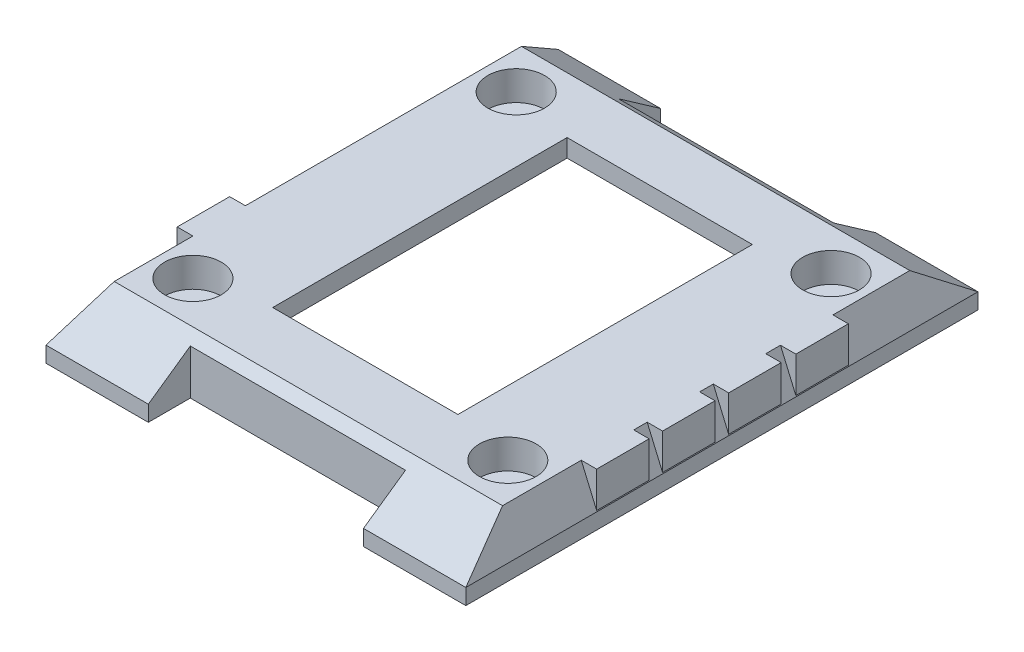
from build123d import *

# Parameters (mm, degrees)
SKETCH1_W            = 40
SKETCH1_H            = 48.8
BOSS_EXTRUDE1_DEPTH  = 5
SKETCH2_W            = 20.5
SKETCH2_H            = 8
CUT_EXTRUDE1_DEPTH   = 6
SKETCH3_R            = 2.7
CUT_EXTRUDE2_DEPTH   = 2.8
SKETCH5_R            = 1
CUT_EXTRUDE3_DEPTH   = 6
SKETCH6_OUTSIDE_W    = 63.46
SKETCH6_OUTSIDE_H    = 19.66
CUT_EXTRUDE4_DEPTH   = 41
SKETCH7_OUTSIDE_W    = 54.66
SKETCH7_OUTSIDE_H    = 19.66
CUT_EXTRUDE5_DEPTH   = 49.8
SKETCH8_W            = 17.65
SKETCH8_H            = 28.05
CUT_EXTRUDE6_DEPTH   = 6
BOSS_EXTRUDE2_REACH  = 7
SKETCH9_W            = 2.93050761
SKETCH9_H            = 5
SKETCH9_W_2          = 3
SKETCH10_W           = 35.8
SKETCH10_H           = 38
CUT_EXTRUDE7_DEPTH   = 0.8
SKETCH11_W           = 36
SKETCH11_H           = 24
CUT_EXTRUDE8_DEPTH   = 2.8
SKETCH12_W           = 4
SKETCH12_H           = 26.7
CUT_EXTRUDE9_DEPTH   = 3.3
SKETCH13_OUTSIDE_W   = 54.66
SKETCH13_OUTSIDE_H   = 63.46
SKETCH13_OUTSIDE_W_2 = 40
SKETCH13_OUTSIDE_H_2 = 48.8
CUT_EXTRUDE10_DEPTH  = 3.3
SKETCH14_W           = 3.8
SKETCH14_H           = 4.5
FILLET1_R            = 2


with BuildPart() as part:
    # Sketch1 → Boss-Extrude1 (new body)
    with BuildSketch(Plane(origin=(0, 0, 0), x_dir=(1, 0, 0), z_dir=(0, 1, 0))):
        with Locations((-15.144927536, 0.78115942)):
            Rectangle(SKETCH1_W, SKETCH1_H)
    extrude(amount=BOSS_EXTRUDE1_DEPTH)

    # Sketch2 → Cut-Extrude1 (cut, through all)
    with BuildSketch(Plane(origin=(0, 5, 0), x_dir=(1, 0, 0), z_dir=(0, 1, 0))):
        with Locations((-15.144927536, -23.61884058)):
            Rectangle(SKETCH2_W, SKETCH2_H)
        with Locations((-15.144927536, 25.18115942)):
            Rectangle(SKETCH2_W, SKETCH2_H)
    extrude(amount=-CUT_EXTRUDE1_DEPTH, mode=Mode.SUBTRACT)

    # Sketch3 → Cut-Extrude2 (cut)
    with BuildSketch(Plane(origin=(0, 5, 0), x_dir=(1, 0, 0), z_dir=(0, 1, 0))):
        with Locations((-30.144927536, 16.18115942)):
            Circle(SKETCH3_R)
        with Locations((-0.144927536, 16.18115942)):
            Circle(SKETCH3_R)
        with Locations((-30.144927536, -14.61884058)):
            Circle(SKETCH3_R)
        with Locations((-0.144927536, -14.61884058)):
            Circle(SKETCH3_R)
    extrude(amount=-CUT_EXTRUDE2_DEPTH, mode=Mode.SUBTRACT)

    # Sketch5 → Cut-Extrude3 (cut, through all)
    with BuildSketch(Plane(origin=(0, 5, 0), x_dir=(1, 0, 0), z_dir=(0, 1, 0))):
        with Locations((-30.144927536, -14.61884058)):
            Circle(SKETCH5_R)
        with Locations((-0.144927536, -14.61884058)):
            Circle(SKETCH5_R)
        with Locations((-0.144927536, 16.18115942)):
            Circle(SKETCH5_R)
        with Locations((-30.144927536, 16.18115942)):
            Circle(SKETCH5_R)
    extrude(amount=-CUT_EXTRUDE3_DEPTH, mode=Mode.SUBTRACT)

    # Sketch6 outside → Cut-Extrude4 (cut, through all)
    with BuildSketch(Plane(origin=(4.855072464, 0, 0), x_dir=(0, 0, -1), z_dir=(1, 0, 0))):
        with Locations((0.781, 2.5)):
            Rectangle(SKETCH6_OUTSIDE_W, SKETCH6_OUTSIDE_H)
        Polygon((-18.61884058, 5), (-23.61884058, 1.5), (-23.61884058, 0), (25.18115942, 0), (25.18115942, 1.5), (20.18115942, 5), align=None, mode=Mode.SUBTRACT)
    extrude(amount=-CUT_EXTRUDE4_DEPTH, mode=Mode.SUBTRACT)

    # Sketch7 outside → Cut-Extrude5 (cut, through all)
    with BuildSketch(Plane.XY.offset(23.61884058)):
        with Locations((-15.145, 2.5)):
            Rectangle(SKETCH7_OUTSIDE_W, SKETCH7_OUTSIDE_H)
        Polygon((4.855072464, 1.5), (3.355072464, 5), (-33.644927536, 5), (-35.144927536, 1.5), (-35.144927536, 0), (4.855072464, 0), align=None, mode=Mode.SUBTRACT)
    extrude(amount=-CUT_EXTRUDE5_DEPTH, mode=Mode.SUBTRACT)

    # Sketch8 → Cut-Extrude6 (cut, through all)
    with BuildSketch(Plane(origin=(0, 5, 0), x_dir=(1, 0, 0), z_dir=(0, 1, 0))):
        with Locations((-15.119927536, 0.80615942)):
            Rectangle(SKETCH8_W, SKETCH8_H)
    extrude(amount=-CUT_EXTRUDE6_DEPTH, mode=Mode.SUBTRACT)

    # Sketch9 → Boss-Extrude2 (add, up to next)
    with BuildSketch(Plane(origin=(0, 5, 0), x_dir=(1, 0, 0), z_dir=(0, 1, 0)), mode=Mode.PRIVATE) as boss_extrude2_sk1:
        with Locations((3.355072464, 10.36115942)):
            Rectangle(SKETCH9_W, SKETCH9_H)
    boss_extrude2_tool1 = extrude(boss_extrude2_sk1.sketch, amount=-BOSS_EXTRUDE2_REACH, mode=Mode.PRIVATE) - part.part
    add(boss_extrude2_tool1.solids().sort_by_distance((3.355072, 5, -10.361159))[0])
    # Sketch9 → Boss-Extrude2 (add, up to next)
    with BuildSketch(Plane(origin=(0, 5, 0), x_dir=(1, 0, 0), z_dir=(0, 1, 0)), mode=Mode.PRIVATE) as boss_extrude2_sk2:
        with Locations((3.355072464, 3.96115942)):
            Rectangle(SKETCH9_W, SKETCH9_H)
    boss_extrude2_tool2 = extrude(boss_extrude2_sk2.sketch, amount=-BOSS_EXTRUDE2_REACH, mode=Mode.PRIVATE) - part.part
    add(boss_extrude2_tool2.solids().sort_by_distance((3.355072, 5, -3.961159))[0])
    # Sketch9 → Boss-Extrude2 (add, up to next)
    with BuildSketch(Plane(origin=(0, 5, 0), x_dir=(1, 0, 0), z_dir=(0, 1, 0)), mode=Mode.PRIVATE) as boss_extrude2_sk3:
        with Locations((3.355072464, -2.33884058)):
            Rectangle(SKETCH9_W, SKETCH9_H)
    boss_extrude2_tool3 = extrude(boss_extrude2_sk3.sketch, amount=-BOSS_EXTRUDE2_REACH, mode=Mode.PRIVATE) - part.part
    add(boss_extrude2_tool3.solids().sort_by_distance((3.355072, 5, 2.338841))[0])
    # Sketch9 → Boss-Extrude2 (add, up to next)
    with BuildSketch(Plane(origin=(0, 5, 0), x_dir=(1, 0, 0), z_dir=(0, 1, 0)), mode=Mode.PRIVATE) as boss_extrude2_sk4:
        with Locations((3.355072464, -8.61884058)):
            Rectangle(SKETCH9_W, SKETCH9_H)
    boss_extrude2_tool4 = extrude(boss_extrude2_sk4.sketch, amount=-BOSS_EXTRUDE2_REACH, mode=Mode.PRIVATE) - part.part
    add(boss_extrude2_tool4.solids().sort_by_distance((3.355072, 5, 8.618841))[0])
    # Sketch9 → Boss-Extrude2 (add, up to next)
    with BuildSketch(Plane(origin=(0, 5, 0), x_dir=(1, 0, 0), z_dir=(0, 1, 0)), mode=Mode.PRIVATE) as boss_extrude2_sk5:
        with Locations((-33.644927536, -8.61884058)):
            Rectangle(SKETCH9_W_2, SKETCH9_H)
    boss_extrude2_tool5 = extrude(boss_extrude2_sk5.sketch, amount=-BOSS_EXTRUDE2_REACH, mode=Mode.PRIVATE) - part.part
    add(boss_extrude2_tool5.solids().sort_by_distance((-33.644928, 5, 8.618841))[0])

    # Sketch10 → Cut-Extrude7 (cut)
    with BuildSketch(Plane.XZ):
        with Locations((-15.144927536, -0.78115942)):
            Rectangle(SKETCH10_W, SKETCH10_H)
    extrude(amount=-CUT_EXTRUDE7_DEPTH, mode=Mode.SUBTRACT)

    # Sketch11 → Cut-Extrude8 (cut)
    with BuildSketch(Plane.XZ):
        with Locations((-15.144927536, -0.78115942)):
            Rectangle(SKETCH11_W, SKETCH11_H)
    extrude(amount=-CUT_EXTRUDE8_DEPTH, mode=Mode.SUBTRACT)

    # Sketch12 → Cut-Extrude9 (cut)
    with BuildSketch(Plane.XZ):
        with Locations((-5.144927536, -0.93115942)):
            Rectangle(SKETCH12_W, SKETCH12_H)
    extrude(amount=-CUT_EXTRUDE9_DEPTH, mode=Mode.SUBTRACT)

    # Sketch13 outside → Cut-Extrude10 (cut)
    with BuildSketch(Plane.XZ):
        with Locations((-15.145, -0.781)):
            Rectangle(SKETCH13_OUTSIDE_W, SKETCH13_OUTSIDE_H)
        with Locations((-15.144927536, -0.78115942)):
            Rectangle(SKETCH13_OUTSIDE_W_2, SKETCH13_OUTSIDE_H_2, mode=Mode.SUBTRACT)
        Polygon((2.855072464, -13.18115942), (-3.144927536, -13.18115942), (-3.144927536, -19.776149343), (-27.144927536, -19.78115942), (-27.144927536, -13.18115942), (-33.144927536, -13.18115942), (-33.144927536, 11.61884058), (-27.144927536, 11.61884058), (-27.144927536, 18.21884058), (-3.144927536, 18.21884058), (-3.144927536, 11.61884058), (2.855072464, 11.61884058), align=None)
    extrude(amount=-CUT_EXTRUDE10_DEPTH, mode=Mode.SUBTRACT)

    # Sketch14 → Cut-Revolve1 (revolve, cut)
    with BuildSketch(Plane.XZ):
        with Locations((-32.544927536, -10.73115942)):
            Rectangle(SKETCH14_W, SKETCH14_H)
    revolve(axis=Axis((-30.644927536, 0, -16.414338521), (0, 0, 1)), mode=Mode.SUBTRACT)

    # Fillet1
    fillet1_edges = [part.edges().sort_by_distance(p)[0] for p in [
        (-3.144927536, 2.05, -13.18115942),
        (-27.144927536, 2.05, -13.18115942),
        (-27.144927536, 2.05, 11.61884058),
        (-3.144927536, 2.05, 11.61884058),
    ]]
    fillet(fillet1_edges, radius=FILLET1_R)


solid = part.part
